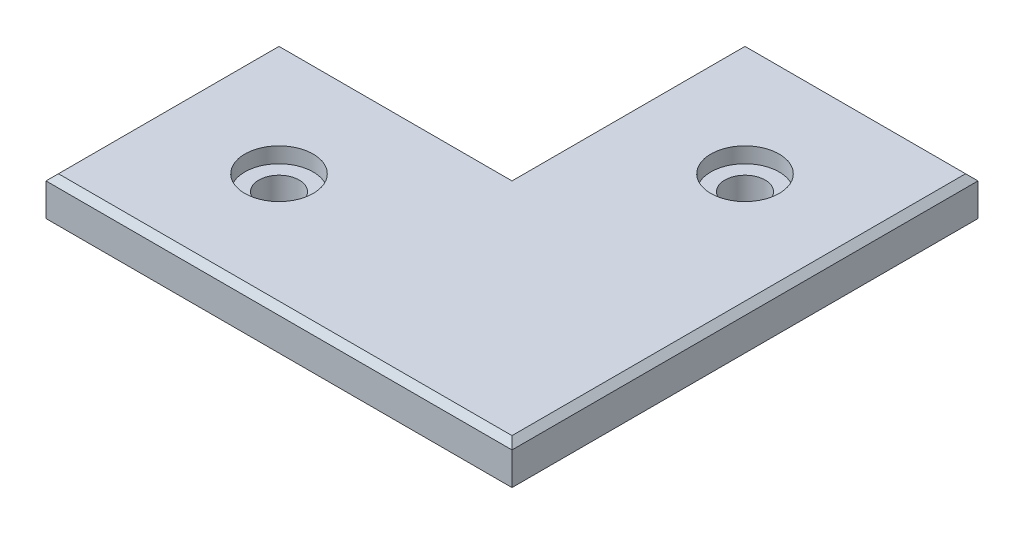
from build123d import *

# Parameters (mm, degrees)
BOSS_EXTRUDE1_DEPTH = 6.35
SKETCH3_R           = 3.302
CUT_EXTRUDE2_DEPTH  = 6.35
SKETCH4_R           = 5.588
CUT_EXTRUDE3_DEPTH  = 2.54
CHAMFER1_SIZE       = 1.016


with BuildPart() as part:
    # Sketch1 → Boss-Extrude1 (new body)
    with BuildSketch(Plane(origin=(0, 0, 0), x_dir=(1, 0, 0), z_dir=(0, 1, 0))):
        Polygon((-7.240727314, -173.10442994), (68.959272686, -173.10442994), (68.959272686, -96.90442994), (30.859272686, -96.90442994), (30.859272686, -135.00442994), (-7.240727314, -135.00442994), align=None)
    extrude(amount=BOSS_EXTRUDE1_DEPTH)

    # Sketch3 → Cut-Extrude2 (cut)
    with BuildSketch(Plane(origin=(0, 0, 0), x_dir=(1, 0, 0), z_dir=(0, 1, 0))):
        with Locations((11.809272686, -154.05442994)):
            Circle(SKETCH3_R)
        with Locations((49.909272686, -115.95442994)):
            Circle(SKETCH3_R)
    extrude(amount=CUT_EXTRUDE2_DEPTH, mode=Mode.SUBTRACT)

    # Sketch4 → Cut-Extrude3 (cut)
    with BuildSketch(Plane(origin=(0, 6.35, 0), x_dir=(1, 0, 0), z_dir=(0, 1, 0))):
        with Locations((11.809272686, -154.05442994)):
            Circle(SKETCH4_R)
        with Locations((49.909272686, -115.95442994)):
            Circle(SKETCH4_R)
    extrude(amount=-CUT_EXTRUDE3_DEPTH, mode=Mode.SUBTRACT)

    # Chamfer1
    chamfer1_edges = [part.edges().sort_by_distance(p)[0] for p in [
        (11.809272686, 6.35, 135.00442994),
        (-7.240727314, 6.35, 154.05442994),
        (30.859272686, 6.35, 173.10442994),
        (68.959272686, 6.35, 135.00442994),
        (49.909272686, 6.35, 96.90442994),
        (30.859272686, 6.35, 115.95442994),
    ]]
    chamfer(chamfer1_edges, length=CHAMFER1_SIZE)


solid = part.part
